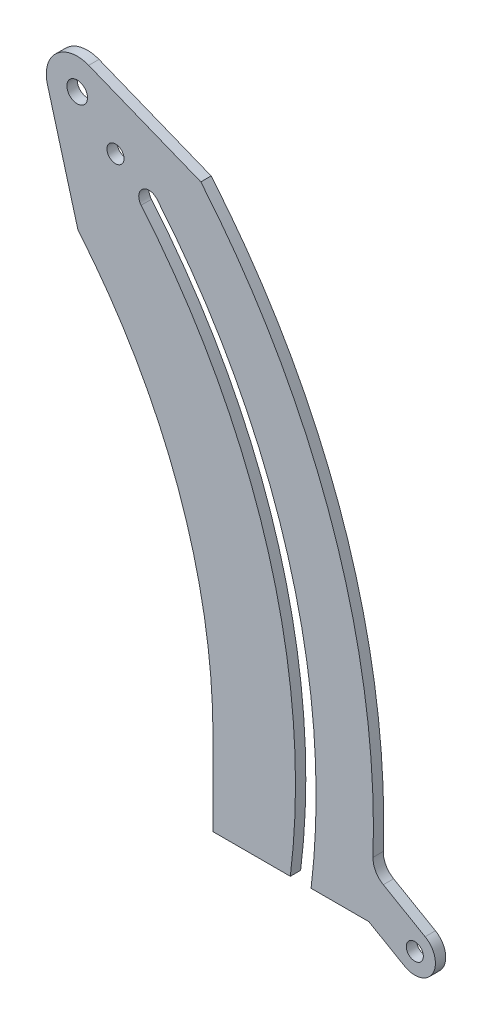
from build123d import *

# Parameters (mm, degrees)
COPIED_SKETCH_DONT_MESS_WITH_DEPTH = 3.175
SKETCH3_R                          = 3.175
HOLE_FOR_TOP_SUPPORT_BRACING_DEPTH = 4.175
SKETCH4_R                          = 3.175
MAKING_IT_MACHINABLE_DEPTH         = 4.175
SKETCH5_R                          = 2.6289
THING_FOR_HARDSTOP_DEPTH           = 3.175
FILLET1_R                          = 6.35
SKETCH6_R                          = 2.6289
CUT_EXTRUDE1_DEPTH                 = 4.175


with BuildPart() as part:
    # Sketch2 → Copied sketch - dont mess with (new body)
    with BuildSketch(Plane.XY):
        with BuildLine():
            Line((155.660230842, 130.614442288), (160.524613056, 134.69614361))
            ThreePointArc((160.524613056, 134.69614361), (200.900960932, 59.581930119), (208.004909798, -25.4))
            Line((208.004909798, -25.4), (225.775729431, -25.4))
            ThreePointArc((225.775729431, -25.4), (217.513785946, 65.632255207), (174.045297477, 146.041344921))
            Line((174.045297477, 146.041344921), (139.503343029, 159.851365822))
            ThreePointArc((139.503343029, 159.851365822), (129.618020291, 158.107153482), (126.784391338, 148.47738561))
            Line((126.784391338, 148.47738561), (136.202701987, 114.287637002))
            ThreePointArc((136.202701987, 114.287637002), (167.077347976, 60.811181483), (177.8, 0))
            Line((177.8, 0), (177.8, -25.4))
            Line((177.8, -25.4), (201.606249903, -25.4))
            ThreePointArc((201.606249903, -25.4), (194.922962004, 57.404519712), (155.660230842, 130.614442288))
        make_face()
    extrude(amount=COPIED_SKETCH_DONT_MESS_WITH_DEPTH)

    # Sketch3 → Hole for top support bracing (cut, through all)
    with BuildSketch(Plane.XY.offset(3.175)):
        with Locations((135.967339212, 151.007028537)):
            Circle(SKETCH3_R)
    extrude(amount=-HOLE_FOR_TOP_SUPPORT_BRACING_DEPTH, mode=Mode.SUBTRACT)

    # Sketch4 → Making it machinable (cut, through all)
    with BuildSketch(Plane.XY.offset(3.175)):
        with Locations((158.092421949, 132.655292949)):
            Circle(SKETCH4_R)
    extrude(amount=-MAKING_IT_MACHINABLE_DEPTH, mode=Mode.SUBTRACT)

    # Sketch5 → Thing for hardstop (add)
    with BuildSketch(Plane.XY.offset(3.175)):
        with BuildLine():
            Line((225.775729431, -25.4), (236.774252059, -31.75))
            ThreePointArc((236.774252059, -31.75), (245.448513373, -29.425738686), (243.124252059, -20.751477372))
            Line((243.124252059, -20.751477372), (226.914188257, -11.392592672))
            ThreePointArc((226.914188257, -11.392592672), (226.453289353, -18.405100951), (225.775729431, -25.4))
        make_face()
        with Locations((239.949252059, -26.250738686)):
            Circle(SKETCH5_R, mode=Mode.SUBTRACT)
    extrude(amount=-THING_FOR_HARDSTOP_DEPTH)

    # Fillet1
    fillet1_edges = [part.edges().sort_by_distance(p)[0] for p in [
        (226.914188257, -11.392592672, 1.5875),
    ]]
    fillet(fillet1_edges, radius=FILLET1_R)

    # Sketch6 → Cut-Extrude1 (cut, through all)
    with BuildSketch(Plane.XY.offset(3.175)):
        with Locations((147.764763317, 140.384580161)):
            Circle(SKETCH6_R)
    extrude(amount=-CUT_EXTRUDE1_DEPTH, mode=Mode.SUBTRACT)


solid = part.part
